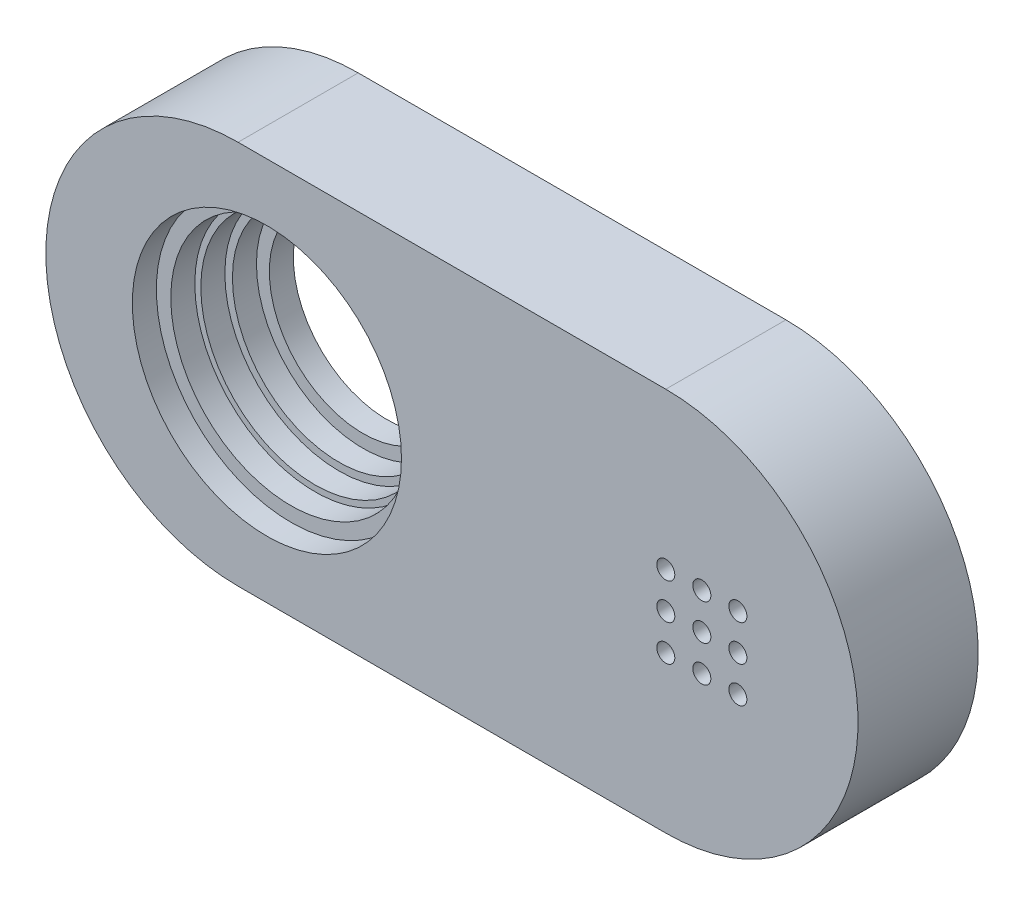
from build123d import *

# Parameters (mm, degrees)
BOSS_EXTRUDE1_DEPTH = 5
SKETCH2_R           = 3.9
CUT_EXTRUDE1_DEPTH  = 5
SKETCH3_R           = 4.435
CUT_EXTRUDE2_DEPTH  = 4
SKETCH4_R           = 4.75
CUT_EXTRUDE3_DEPTH  = 3
SKETCH5_R           = 5
CUT_EXTRUDE4_DEPTH  = 2
SKETCH6_R           = 5.6
CUT_EXTRUDE5_DEPTH  = 1
SKETCH7_R           = 0.375
CUT_EXTRUDE6_DEPTH  = 6


with BuildPart() as part:
    # Sketch1 → Boss-Extrude1 (new body)
    with BuildSketch(Plane.XY):
        with BuildLine():
            Line((-8.9, 8), (8.9, 8))
            ThreePointArc((8.9, 8), (16.9, 0), (8.9, -8))
            Line((8.9, -8), (-8.9, -8))
            ThreePointArc((-8.9, -8), (-16.9, 0), (-8.9, 8))
        make_face()
    extrude(amount=BOSS_EXTRUDE1_DEPTH)

    # Sketch2 → Cut-Extrude1 (cut)
    with BuildSketch(Plane.XY.offset(5)):
        with Locations((-7.7, 0)):
            Circle(SKETCH2_R)
    extrude(amount=-CUT_EXTRUDE1_DEPTH, mode=Mode.SUBTRACT)

    # Sketch3 → Cut-Extrude2 (cut)
    with BuildSketch(Plane.XY.offset(5)):
        with Locations((-7.7, 0)):
            Circle(SKETCH3_R)
    extrude(amount=-CUT_EXTRUDE2_DEPTH, mode=Mode.SUBTRACT)

    # Sketch4 → Cut-Extrude3 (cut)
    with BuildSketch(Plane.XY.offset(5)):
        with Locations((-7.7, 0)):
            Circle(SKETCH4_R)
    extrude(amount=-CUT_EXTRUDE3_DEPTH, mode=Mode.SUBTRACT)

    # Sketch5 → Cut-Extrude4 (cut)
    with BuildSketch(Plane.XY.offset(5)):
        with Locations((-7.7, 0)):
            Circle(SKETCH5_R)
    extrude(amount=-CUT_EXTRUDE4_DEPTH, mode=Mode.SUBTRACT)

    # Sketch6 → Cut-Extrude5 (cut)
    with BuildSketch(Plane.XY.offset(5)):
        with Locations((-7.7, 0)):
            Circle(SKETCH6_R)
    extrude(amount=-CUT_EXTRUDE5_DEPTH, mode=Mode.SUBTRACT)

    # Sketch7 → Cut-Extrude6 (cut, through all)
    with BuildSketch(Plane.XY.offset(5)):
        with Locations((10.4, 0)):
            Circle(SKETCH7_R)
        with Locations((8.9, 0)):
            Circle(SKETCH7_R)
        with Locations((11.9, 0)):
            Circle(SKETCH7_R)
        with Locations((8.9, -1.5)):
            Circle(SKETCH7_R)
        with Locations((10.4, -1.5)):
            Circle(SKETCH7_R)
        with Locations((11.9, -1.5)):
            Circle(SKETCH7_R)
        with Locations((8.9, 1.5)):
            Circle(SKETCH7_R)
        with Locations((10.4, 1.5)):
            Circle(SKETCH7_R)
        with Locations((11.9, 1.5)):
            Circle(SKETCH7_R)
    extrude(amount=-CUT_EXTRUDE6_DEPTH, mode=Mode.SUBTRACT)


solid = part.part
